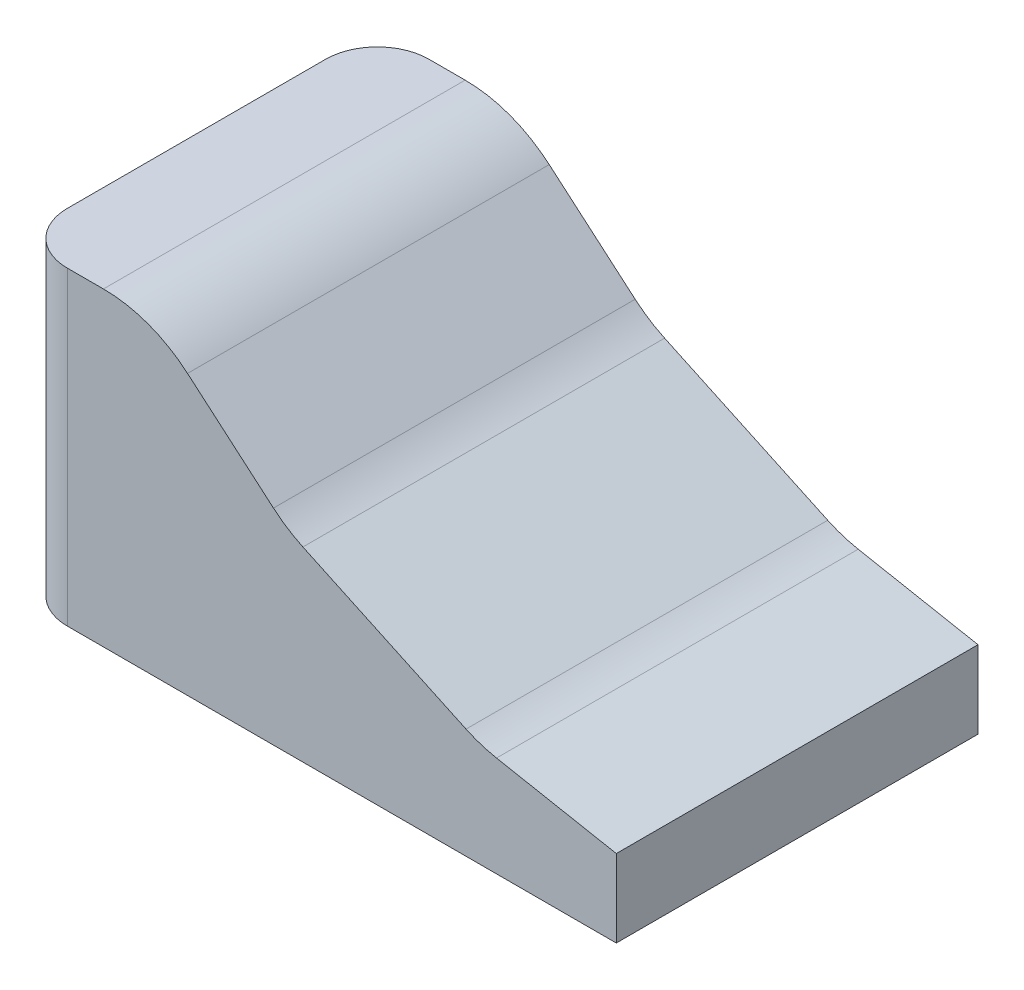
from build123d import *

# Parameters (mm, degrees)
EXTRUDE1_DEPTH = 177.8
FILLET1_R      = 63.5
FILLET2_R      = 25.4


with BuildPart() as part:
    # Sketch1 → Extrude1 (new body)
    with BuildSketch(Plane.XY):
        Polygon((0, 152.4), (0, 0), (295.275, 0), (295.275, 38.1), (228.6, 50.8), (133.35, 95.25), (66.675, 152.4), align=None)
    extrude(amount=-EXTRUDE1_DEPTH)

    # Fillet1
    fillet1_edges = [part.edges().sort_by_distance(p)[0] for p in [
        (228.6, 50.8, -88.9),
        (66.675, 152.4, -88.9),
        (133.35, 95.25, -88.9),
    ]]
    fillet(fillet1_edges, radius=FILLET1_R)

    # Fillet2
    fillet2_edges = [part.edges().sort_by_distance(p)[0] for p in [
        (0, 76.2, -177.8),
        (0, 76.2, 0),
    ]]
    fillet(fillet2_edges, radius=FILLET2_R)


solid = part.part
